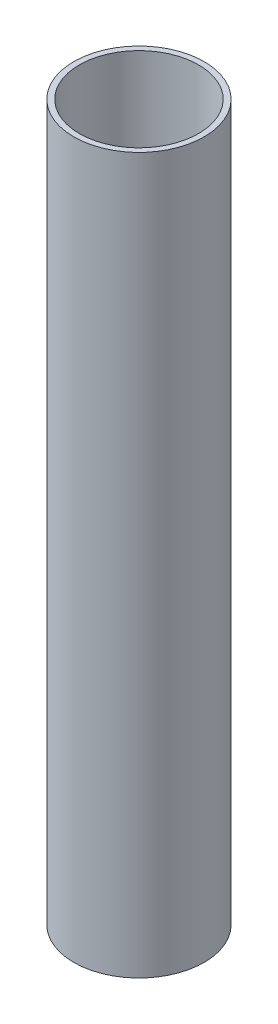
from build123d import *

# Parameters (mm, degrees)
SKETCH1_R           = 41.6814
SKETCH1_R_2         = 38.1
BOSS_EXTRUDE1_DEPTH = 457.2


with BuildPart() as part:
    # Sketch1 → Boss-Extrude1 (new body)
    with BuildSketch(Plane(origin=(0, 0, 0), x_dir=(1, 0, 0), z_dir=(0, 1, 0))):
        Circle(SKETCH1_R)
        Circle(SKETCH1_R_2, mode=Mode.SUBTRACT)
    extrude(amount=BOSS_EXTRUDE1_DEPTH)


solid = part.part
